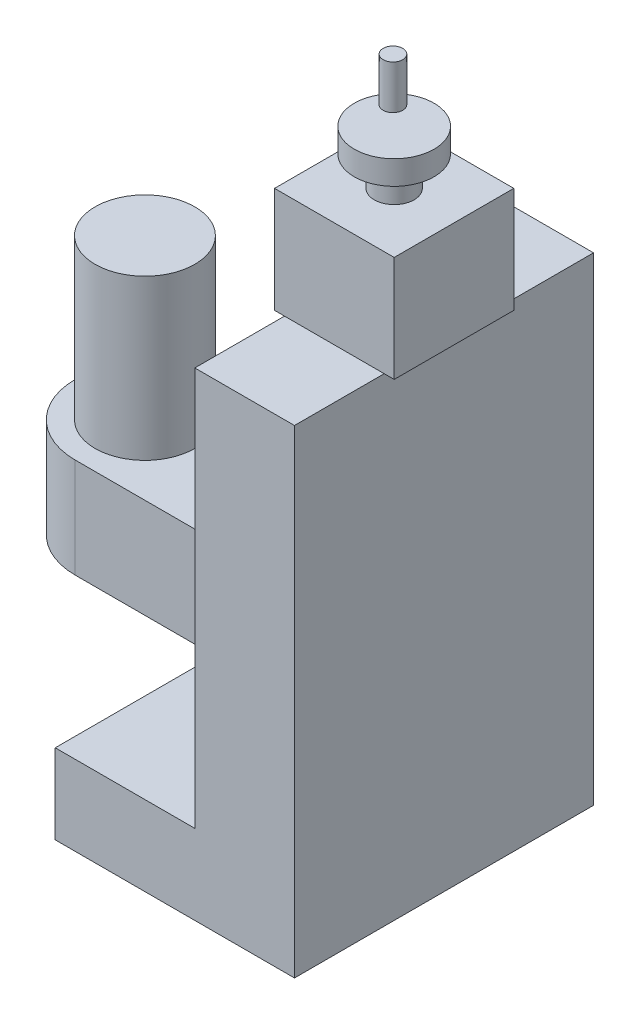
from build123d import *

# Parameters (mm, degrees)
EXTRUDE_1_DEPTH = 150
EXTRUDE_2_DEPTH = 50
SKETCH_4_R      = 25
EXTRUDE_3_DEPTH = 80
SKETCH_5_W      = 60
SKETCH_5_H      = 60
EXTRUDE_4_DEPTH = 53
SKETCH_6_R      = 10
EXTRUDE_5_DEPTH = 15
SKETCH_7_R      = 20
EXTRUDE_6_DEPTH = 12
SKETCH_8_R      = 4.914054778
EXTRUDE_7_DEPTH = 22


with BuildPart() as part:
    # ｽｹｯﾁ1 → ﾎﾞｽ - 押し出し1 (new body)
    with BuildSketch(Plane.XY):
        Polygon((0, 0), (120, 0), (120, 240), (70, 240), (70, 40), (0, 40), align=None)
    extrude(amount=EXTRUDE_1_DEPTH)

    # ｽｹｯﾁ3 → ﾎﾞｽ - 押し出し2 (add)
    with BuildSketch(Plane(origin=(0, 80, 0), x_dir=(1, 0, 0), z_dir=(0, 1, 0))):
        with BuildLine():
            Line((70, -40), (-30, -40))
            ThreePointArc((-30, -40), (-65, -75), (-30, -110))
            Line((-30, -110), (70, -110))
            Line((70, -110), (70, -40))
        make_face()
    extrude(amount=EXTRUDE_2_DEPTH)

    # ｽｹｯﾁ4 → ﾎﾞｽ - 押し出し3 (add)
    with BuildSketch(Plane(origin=(0, 130, 0), x_dir=(1, 0, 0), z_dir=(0, 1, 0))):
        with Locations((-29.999997022, -75)):
            Circle(SKETCH_4_R)
    extrude(amount=EXTRUDE_3_DEPTH)

    # ｽｹｯﾁ5 → ﾎﾞｽ - 押し出し4 (add)
    with BuildSketch(Plane(origin=(0, 240, 0), x_dir=(1, 0, 0), z_dir=(0, 1, 0))):
        with Locations((95, -75)):
            Rectangle(SKETCH_5_W, SKETCH_5_H)
    extrude(amount=EXTRUDE_4_DEPTH)

    # ｽｹｯﾁ6 → ﾎﾞｽ - 押し出し5 (add)
    with BuildSketch(Plane(origin=(0, 293, 0), x_dir=(1, 0, 0), z_dir=(0, 1, 0))):
        with Locations((95, -75)):
            Circle(SKETCH_6_R)
    extrude(amount=EXTRUDE_5_DEPTH)

    # ｽｹｯﾁ7 → ﾎﾞｽ - 押し出し6 (add)
    with BuildSketch(Plane(origin=(0, 308, 0), x_dir=(1, 0, 0), z_dir=(0, 1, 0))):
        with Locations((95, -75)):
            Circle(SKETCH_7_R)
    extrude(amount=EXTRUDE_6_DEPTH)

    # ｽｹｯﾁ8 → ﾎﾞｽ - 押し出し7 (add)
    with BuildSketch(Plane(origin=(0, 320, 0), x_dir=(1, 0, 0), z_dir=(0, 1, 0))):
        with Locations((85.328318408, -65.952959142)):
            Circle(SKETCH_8_R)
    extrude(amount=EXTRUDE_7_DEPTH)


solid = part.part
